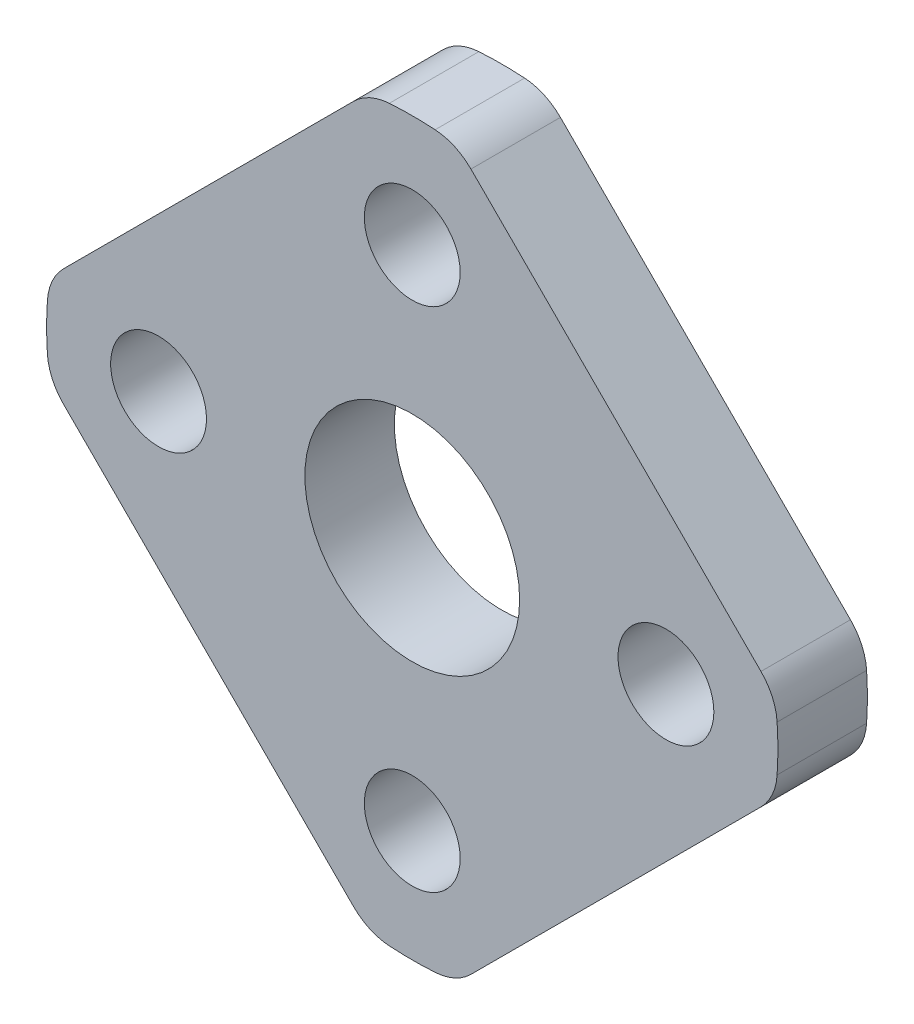
from build123d import *

# Parameters (mm, degrees)
SKETCH1_R           = 1.7
SKETCH1_R_2         = 3.81
BOSS_EXTRUDE1_DEPTH = 3.175


with BuildPart() as part:
    # Sketch1 → Boss-Extrude1 (new body)
    with BuildSketch(Plane.XY):
        with BuildLine():
            Line((-2.081852397, 12.371410211), (-12.371410211, 2.081852397))
            ThreePointArc((-12.371410211, 2.081852397), (-12.773942372, 1.499384559), (-12.944543252, 0.812219176))
            ThreePointArc((-12.944543252, 0.812219176), (-12.97, 0), (-12.944543252, -0.812219176))
            ThreePointArc((-12.944543252, -0.812219176), (-12.773942372, -1.499384559), (-12.371410211, -2.081852397))
            Line((-12.371410211, -2.081852397), (-2.081852397, -12.371410211))
            ThreePointArc((-2.081852397, -12.371410211), (-1.499384559, -12.773942372), (-0.812219176, -12.944543252))
            ThreePointArc((-0.812219176, -12.944543252), (0, -12.97), (0.812219176, -12.944543252))
            ThreePointArc((0.812219176, -12.944543252), (1.499384559, -12.773942372), (2.081852397, -12.371410211))
            Line((2.081852397, -12.371410211), (12.371410211, -2.081852397))
            ThreePointArc((12.371410211, -2.081852397), (12.773942372, -1.499384559), (12.944543252, -0.812219176))
            ThreePointArc((12.944543252, -0.812219176), (12.97, 0), (12.944543252, 0.812219176))
            ThreePointArc((12.944543252, 0.812219176), (12.773942372, 1.499384559), (12.371410211, 2.081852397))
            Line((12.371410211, 2.081852397), (2.081852397, 12.371410211))
            ThreePointArc((2.081852397, 12.371410211), (1.499384559, 12.773942372), (0.812219176, 12.944543252))
            ThreePointArc((0.812219176, 12.944543252), (0, 12.97), (-0.812219176, 12.944543252))
            ThreePointArc((-0.812219176, 12.944543252), (-1.499384559, 12.773942372), (-2.081852397, 12.371410211))
        make_face()
        with Locations((0, -9)):
            Circle(SKETCH1_R, mode=Mode.SUBTRACT)
        with Locations((-9, 0)):
            Circle(SKETCH1_R, mode=Mode.SUBTRACT)
        with Locations((0, 9)):
            Circle(SKETCH1_R, mode=Mode.SUBTRACT)
        with Locations((9, 0)):
            Circle(SKETCH1_R, mode=Mode.SUBTRACT)
        Circle(SKETCH1_R_2, mode=Mode.SUBTRACT)
    extrude(amount=BOSS_EXTRUDE1_DEPTH)


solid = part.part
